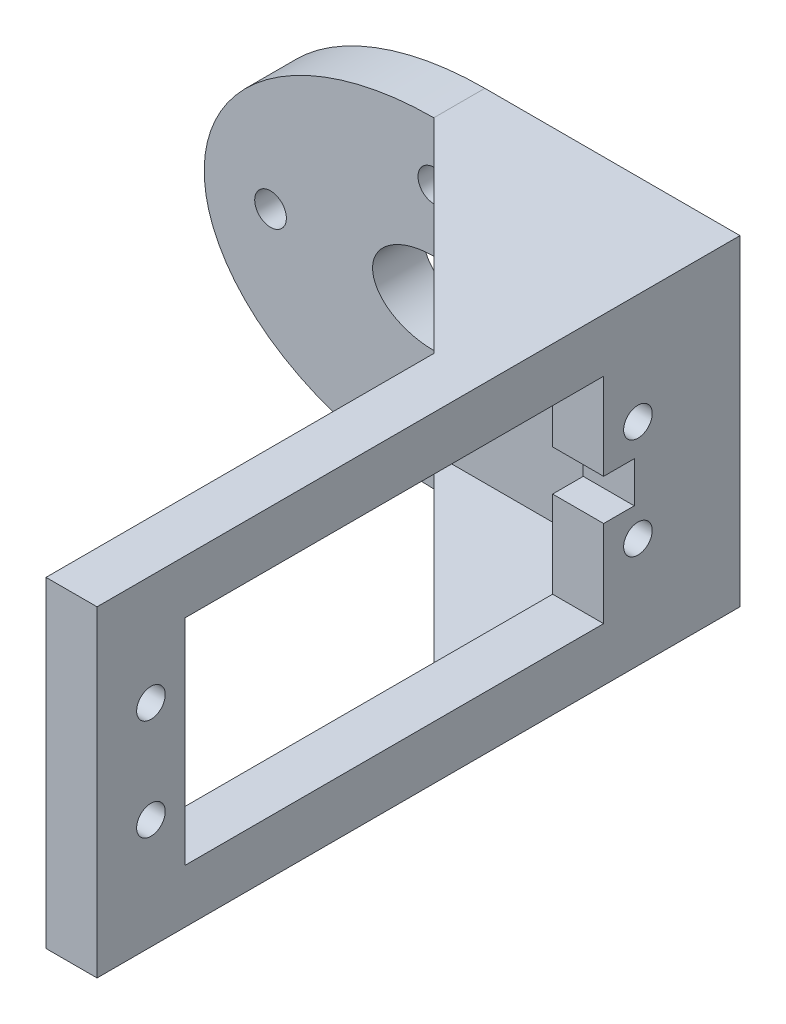
from build123d import *

# Parameters (mm, degrees)
ESQUISSE1_R             = 1.55
BOSS_EXTRU_1_DEPTH      = 5
ESQUISSE3_W             = 5
ESQUISSE3_H             = 31.5
BOSS_EXTRU_2_DEPTH      = 58
ESQUISSE4_R             = 1.4
ENL_V_MAT_EXTRU_1_DEPTH = 5
BOSS_EXTRU_3_DEPTH      = 3
ESQUISSE6_W             = 3
ESQUISSE6_H             = 4
ESQUISSE6_W_2           = 41
ESQUISSE6_H_2           = 21
ENL_V_MAT_EXTRU_2_DEPTH = 5


with BuildPart() as part:
    # Esquisse1 → Boss.-Extru.1 (new body)
    with BuildSketch(Plane.XY):
        with BuildLine():
            Line((25, -15.75), (25, 15.75))
            Line((25, 15.75), (0, 15.75))
            add(Edge.make_bspline(
                [(0, 15.75), (-22.5, 15.75), (-22.5, 0), (-22.5, -15.75), (0, -15.75)],
                knots=[1.570796327, 1.570796327, 1.570796327, 3.141592654, 3.141592654, 4.71238898, 4.71238898, 4.71238898], degree=2, weights=[1, 0.707106781, 1, 0.707106781, 1]))
            Line((0, -15.75), (25, -15.75))
        make_face()
        with Locations((0, 10)):
            Circle(ESQUISSE1_R, mode=Mode.SUBTRACT)
        with Locations((16, 0)):
            Circle(ESQUISSE1_R, mode=Mode.SUBTRACT)
        with Locations((0, -10)):
            Circle(ESQUISSE1_R, mode=Mode.SUBTRACT)
        with Locations((-16, 0)):
            Circle(ESQUISSE1_R, mode=Mode.SUBTRACT)
        with BuildLine():
            add(Edge.make_bspline(
                [(6, 0), (6, 6.92820323), (-3, 3.464101615), (-12, 0), (-3, -3.464101615), (6, -6.92820323), (6, 0)],
                knots=[0, 0, 0, 2.094395102, 2.094395102, 4.188790205, 4.188790205, 6.283185307, 6.283185307, 6.283185307], degree=2, weights=[1, 0.5, 1, 0.5, 1, 0.5, 1]))
        make_face(mode=Mode.SUBTRACT)
    extrude(amount=BOSS_EXTRU_1_DEPTH)

    # Esquisse3 → Boss.-Extru.2 (add)
    with BuildSketch(Plane.XY.offset(5)):
        with Locations((22.5, 0)):
            Rectangle(ESQUISSE3_W, ESQUISSE3_H)
    extrude(amount=BOSS_EXTRU_2_DEPTH)

    # Esquisse4 → Enlèv. mat.-Extru.1 (cut)
    with BuildSketch(Plane.ZY.offset(-20)):
        with Locations((10, 4.96)):
            Circle(ESQUISSE4_R)
        with Locations((10, -4.96)):
            Circle(ESQUISSE4_R)
        with Locations((57.72, -4.96)):
            Circle(ESQUISSE4_R)
        with Locations((57.72, 4.96)):
            Circle(ESQUISSE4_R)
    extrude(amount=-ENL_V_MAT_EXTRU_1_DEPTH, mode=Mode.SUBTRACT)

    # Esquisse5 → Boss.-Extru.3 (add)
    with BuildSketch(Plane(origin=(0, 15.75, 0), x_dir=(1, 0, 0), z_dir=(0, 1, 0))):
        Polygon((0, -5), (20, -5), (20, -25), align=None)
    boss_extru_3 = extrude(amount=-BOSS_EXTRU_3_DEPTH)

    # Symétrie1: Boss.-Extru.3 across plane
    add(boss_extru_3.mirror(Plane.ZX))

    # Esquisse6 → Enlèv. mat.-Extru.2 (cut)
    with BuildSketch(Plane.ZY.offset(-20)):
        with Locations((11.86, 0)):
            Rectangle(ESQUISSE6_W, ESQUISSE6_H)
        with Locations((33.86, 0)):
            Rectangle(ESQUISSE6_W_2, ESQUISSE6_H_2)
    extrude(amount=-ENL_V_MAT_EXTRU_2_DEPTH, mode=Mode.SUBTRACT)


solid = part.part
